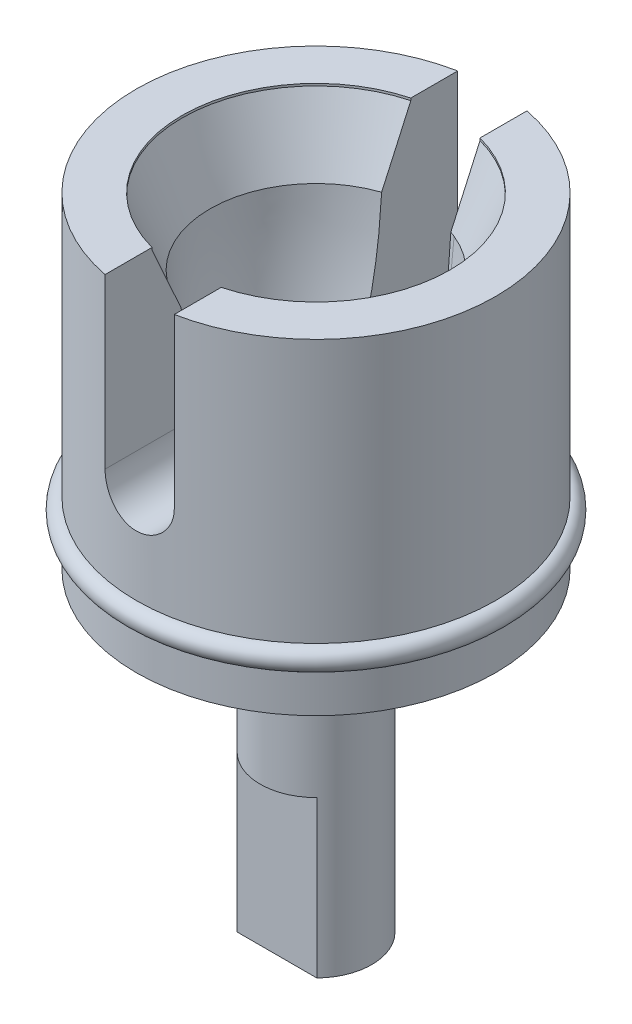
from build123d import *

# Parameters (mm, degrees)
EXTRUDE1_DEPTH = 7
EXTRUDE2_DEPTH = 20.3


with BuildPart() as part:
    # Sketch1 → Revolve1 (revolve)
    with BuildSketch(Plane.XY, mode=Mode.PRIVATE) as revolve1_sk:
        with BuildLine():
            Line((6, 31.680378901), (8.05, 31.680378901))
            Line((8.05, 31.680378901), (8.05, 19.880378901))
            ThreePointArc((8.05, 19.880378901), (8.55, 19.380378901), (8.05, 18.880378901))
            Line((8.05, 18.880378901), (8.05, 17.080378901))
            Line((8.05, 17.080378901), (3.5, 17.080378901))
            Line((3.5, 17.080378901), (3.5, 15.680378901))
            Line((3.5, 15.680378901), (2.5, 15.680378901))
            Line((2.5, 15.680378901), (2.5, 2.980378901))
            Line((2.5, 2.980378901), (0, 2.980378901))
            Line((0, 2.980378901), (0, 20.880378901))
            Line((0, 20.880378901), (0.5, 20.880378901))
            add(Edge.make_bspline(
                [(0.5, 20.880378901), (0.932106432, 20.906651763), (1.887530423, 20.96474329), (3.549630763, 21.874391527), (4.219232089, 24.338558209), (4.618386004, 26.623285295), (4.718036301, 28.180794336), (4.75, 28.680378901)],
                knots=[0, 0, 0, 0, 0.130075309, 0.287607547, 0.531387804, 0.849688564, 1, 1, 1, 1], degree=3))
            Line((4.75, 28.680378901), (6, 31.580378901))
            Line((6, 31.580378901), (6, 31.680378901))
        make_face()
    revolve(revolve1_sk.sketch.rotate(Axis((0, 0, 0), (0, 1, 0)), 90), axis=Axis((0, 0, 0), (0, 1, 0)))  # turned: the seam where the file's is

    # Sketch2 → Extrude1 (cut)
    with BuildSketch(Plane.XZ.offset(-2.980378901)):
        Polygon((1.785357107, 1.75), (4.264804166, 1.75), (0.483637586, 4.675163329), (-4.469983747, 1.75), align=None)
        Polygon((-4.469983747, -1.75), (4.264804166, -1.75), (0.383778189, -4.04178496), align=None)
    extrude(amount=-EXTRUDE1_DEPTH, mode=Mode.SUBTRACT)

    # Sketch3 → Extrude2 (cut, through all)
    with BuildSketch(Plane.XY.offset(10.75)):
        with BuildLine():
            Line((-1.55, 37.698212451), (1.55, 37.698212451))
            Line((1.55, 37.698212451), (1.55, 24.130378901))
            ThreePointArc((1.55, 24.130378901), (0, 22.580378901), (-1.55, 24.130378901))
            Line((-1.55, 24.130378901), (-1.55, 37.698212451))
        make_face()
    extrude(amount=-EXTRUDE2_DEPTH, mode=Mode.SUBTRACT)


solid = part.part
